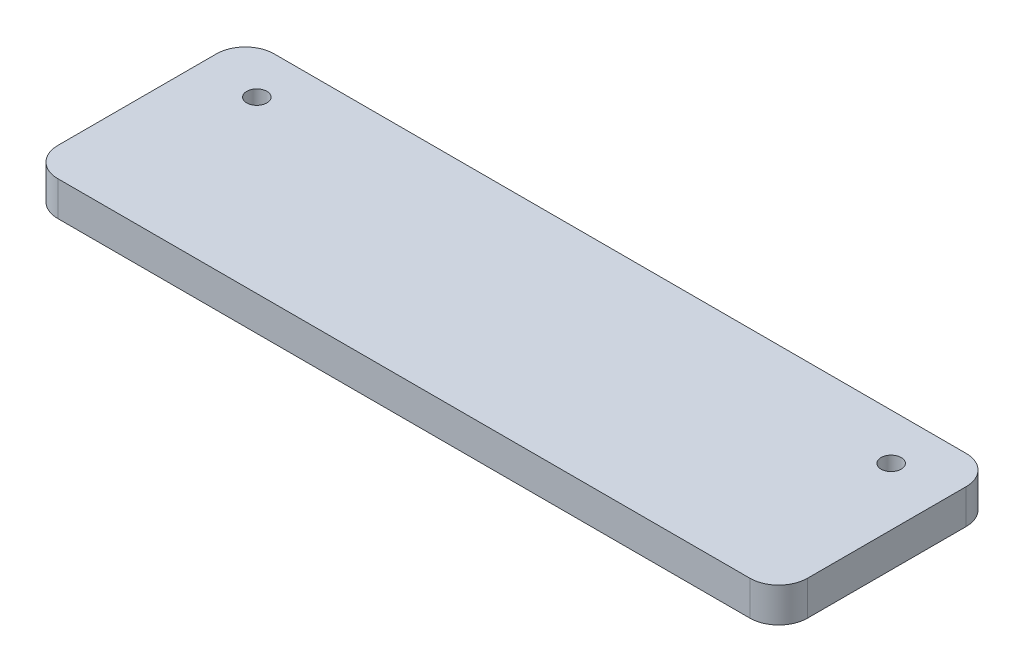
from build123d import *

# Parameters (mm, degrees)
SKETCH1_W           = 130
SKETCH1_H           = 37.5
BOSS_EXTRUDE1_DEPTH = 6
FILLET1_R           = 5
SKETCH2_R           = 1.75
CUT_EXTRUDE1_DEPTH  = 6


with BuildPart() as part:
    # Sketch1 → Boss-Extrude1 (new body)
    with BuildSketch(Plane(origin=(0, 0, 0), x_dir=(1, 0, 0), z_dir=(0, 1, 0))):
        with Locations((65, 18.75)):
            Rectangle(SKETCH1_W, SKETCH1_H)
    extrude(amount=BOSS_EXTRUDE1_DEPTH)

    # Fillet1
    fillet1_edges = [part.edges().sort_by_distance(p)[0] for p in [
        (0, 3, -37.5),
        (130, 3, -37.5),
        (130, 3, 0),
        (0, 3, 0),
    ]]
    fillet(fillet1_edges, radius=FILLET1_R)

    # Sketch2 → Cut-Extrude1 (cut)
    with BuildSketch(Plane(origin=(0, 6, 0), x_dir=(1, 0, 0), z_dir=(0, 1, 0))):
        with Locations((10, 29.5)):
            Circle(SKETCH2_R)
        with Locations((120, 29.5)):
            Circle(SKETCH2_R)
    extrude(amount=-CUT_EXTRUDE1_DEPTH, mode=Mode.SUBTRACT)


solid = part.part
